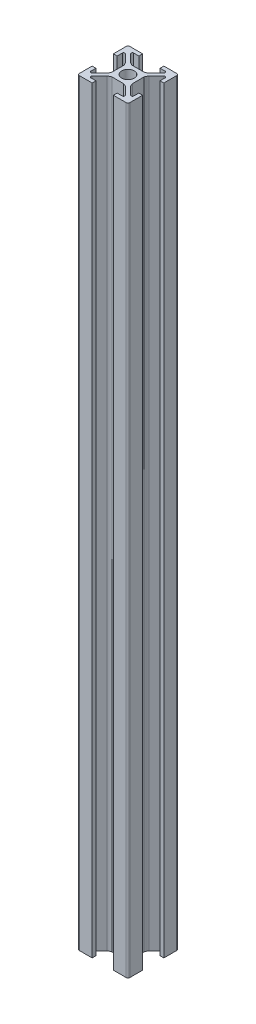
from build123d import *

# Parameters (mm, degrees)
SKETCH1_R           = 2.5
BOSS_EXTRUDE1_DEPTH = 300


with BuildPart() as part:
    # Sketch1 → Boss-Extrude1 (new body)
    with BuildSketch(Plane(origin=(0, 0, 0), x_dir=(1, 0, 0), z_dir=(0, 1, 0))):
        with BuildLine():
            Line((-3.610984523, 4.671644695), (-6.585786438, 7.646446609))
            ThreePointArc((-6.585786438, 7.646446609), (-6.694172813, 8.191341716), (-6.232233047, 8.5))
            Line((-6.232233047, 8.5), (-4.2, 8.5))
            Line((-4.2, 8.5), (-4.2, 10))
            Line((-4.2, 10), (-9.25, 10))
            ThreePointArc((-9.25, 10), (-9.780330086, 9.780330086), (-10, 9.25))
            Line((-10, 9.25), (-10, 4.2))
            Line((-10, 4.2), (-8.5, 4.2))
            Line((-8.5, 4.2), (-8.5, 6.232233047))
            ThreePointArc((-8.5, 6.232233047), (-8.191341716, 6.694172813), (-7.646446609, 6.585786438))
            Line((-7.646446609, 6.585786438), (-4.671644695, 3.610984523))
            ThreePointArc((-4.671644695, 3.610984523), (-4.244383234, 2.985253206), (-4, 2.268058063))
            Line((-4, 2.268058063), (-4, -2.268058063))
            ThreePointArc((-4, -2.268058063), (-4.244383234, -2.985253206), (-4.671644695, -3.610984523))
            Line((-4.671644695, -3.610984523), (-7.646446609, -6.585786438))
            ThreePointArc((-7.646446609, -6.585786438), (-8.191341716, -6.694172813), (-8.5, -6.232233047))
            Line((-8.5, -6.232233047), (-8.5, -4.2))
            Line((-8.5, -4.2), (-10, -4.2))
            Line((-10, -4.2), (-10, -9.25))
            ThreePointArc((-10, -9.25), (-9.780330086, -9.780330086), (-9.25, -10))
            Line((-9.25, -10), (-4.2, -10))
            Line((-4.2, -10), (-4.2, -8.5))
            Line((-4.2, -8.5), (-6.232233047, -8.5))
            ThreePointArc((-6.232233047, -8.5), (-6.694172813, -8.191341716), (-6.585786438, -7.646446609))
            Line((-6.585786438, -7.646446609), (-3.610984523, -4.671644695))
            ThreePointArc((-3.610984523, -4.671644695), (-2.985253206, -4.244383234), (-2.268058063, -4))
            Line((-2.268058063, -4), (2.268058063, -4))
            ThreePointArc((2.268058063, -4), (2.985253206, -4.244383234), (3.610984523, -4.671644695))
            Line((3.610984523, -4.671644695), (6.585786438, -7.646446609))
            ThreePointArc((6.585786438, -7.646446609), (6.694172813, -8.191341716), (6.232233047, -8.5))
            Line((6.232233047, -8.5), (4.2, -8.5))
            Line((4.2, -8.5), (4.2, -10))
            Line((4.2, -10), (9.25, -10))
            ThreePointArc((9.25, -10), (9.780330086, -9.780330086), (10, -9.25))
            Line((10, -9.25), (10, -4.2))
            Line((10, -4.2), (8.5, -4.2))
            Line((8.5, -4.2), (8.5, -6.232233047))
            ThreePointArc((8.5, -6.232233047), (8.191341716, -6.694172813), (7.646446609, -6.585786438))
            Line((7.646446609, -6.585786438), (4.671644695, -3.610984523))
            ThreePointArc((4.671644695, -3.610984523), (4.244383234, -2.985253206), (4, -2.268058063))
            Line((4, -2.268058063), (4, 2.268058063))
            ThreePointArc((4, 2.268058063), (4.244383234, 2.985253206), (4.671644695, 3.610984523))
            Line((4.671644695, 3.610984523), (7.646446609, 6.585786438))
            ThreePointArc((7.646446609, 6.585786438), (8.191341716, 6.694172813), (8.5, 6.232233047))
            Line((8.5, 6.232233047), (8.5, 4.2))
            Line((8.5, 4.2), (10, 4.2))
            Line((10, 4.2), (10, 9.25))
            ThreePointArc((10, 9.25), (9.780330086, 9.780330086), (9.25, 10))
            Line((9.25, 10), (4.2, 10))
            Line((4.2, 10), (4.2, 8.5))
            Line((4.2, 8.5), (6.232233047, 8.5))
            ThreePointArc((6.232233047, 8.5), (6.694172813, 8.191341716), (6.585786438, 7.646446609))
            Line((6.585786438, 7.646446609), (3.610984523, 4.671644695))
            ThreePointArc((3.610984523, 4.671644695), (2.985253206, 4.244383234), (2.268058063, 4))
            Line((2.268058063, 4), (-2.268058063, 4))
            ThreePointArc((-2.268058063, 4), (-2.985253206, 4.244383234), (-3.610984523, 4.671644695))
        make_face()
        Circle(SKETCH1_R, mode=Mode.SUBTRACT)
    extrude(amount=BOSS_EXTRUDE1_DEPTH)


solid = part.part
